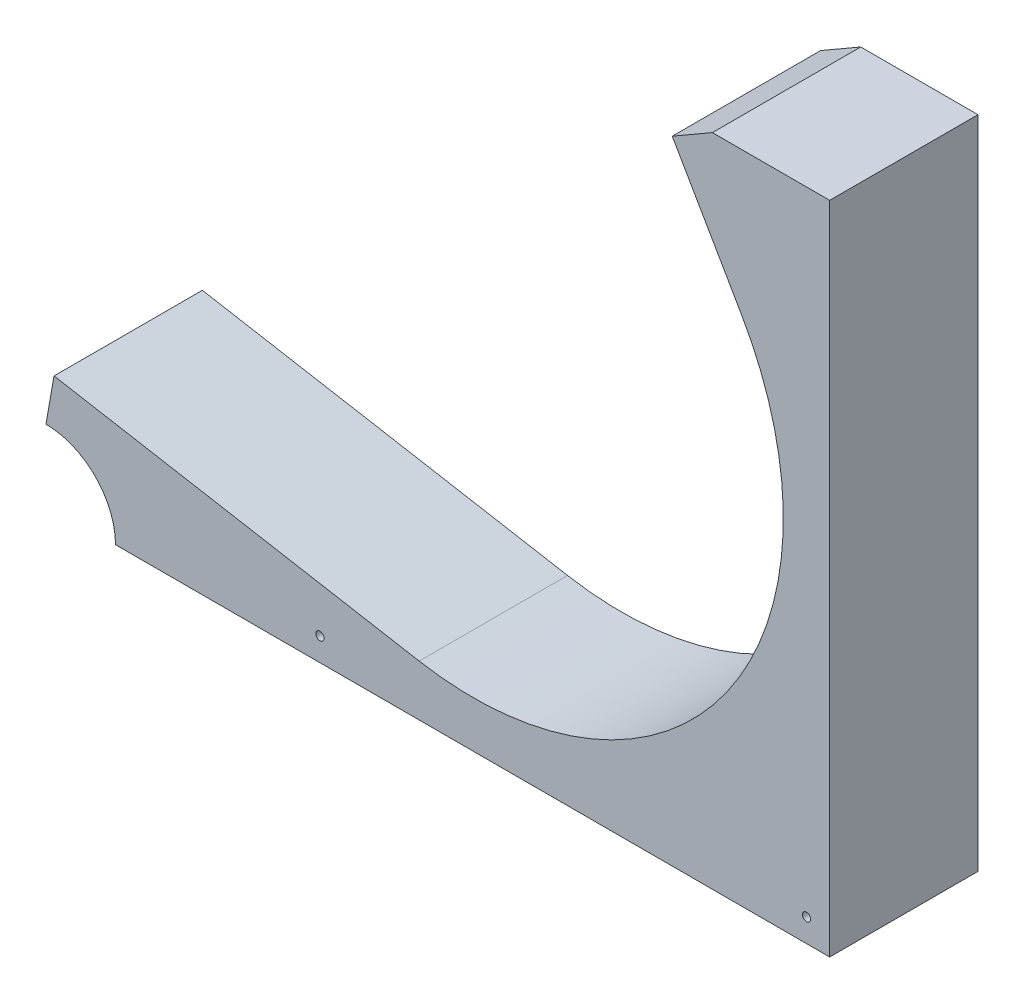
from build123d import *

# Parameters (mm, degrees)
BOSS_EXTRUDE1_DEPTH = 40.64
SKETCH6_R           = 1.1303
CUT_EXTRUDE1_DEPTH  = 158.779215984
SKETCH7_R           = 19.05
CUT_EXTRUDE2_DEPTH  = 158.779215984


with BuildPart() as part:
    # Sweep3: sweep along a path in Sketch2
    with BuildLine(Plane.XY) as sweep3_path:
        Line((-111.378641457, -46.568583299), (-11.322173751, -64.21123815))
        ThreePointArc((-11.322173751, -64.21123815), (53.410187761, -37.398216088), (56.466415172, 32.6009))
        Line((56.466415172, 32.6009), (37.416415172, 65.596467884))
    # 3DSketch1 → Sweep3 (sweep)
    with BuildSketch(Plane(origin=(-117.024291009, -78.586652965, -20.32), x_dir=(0.051794909001673446, 0.2937435257699459, 0.9544799780350292), z_dir=(0.984807753012208, -0.17364817766693055, 0))):
        Polygon((0, 0), (3.788092413, -12.121895721), (42.57815872, 0), (38.790066307, 12.121895721), align=None)
    sweep(path=sweep3_path.line)

    # Sketch5 → Boss-Extrude1 (add)
    with BuildSketch(Plane.XY.offset(20.32)):
        with BuildLine():
            Line((-16.967823303, -96.229307816), (-117.024291009, -78.586652965))
            Line((-117.024291009, -78.586652965), (-117.024291009, -97.7138))
            Line((-117.024291009, -97.7138), (3.02e-07, -97.7138))
            ThreePointArc((3.02e-07, -97.7138), (-8.516318665, -97.341969504), (-16.967823303, -96.229307816))
        make_face()
        with BuildLine():
            ThreePointArc((97.7138, -9e-08), (69.09409067, -69.094090521), (3.02e-07, -97.7138))
            Line((3.02e-07, -97.7138), (97.7138, -97.7138))
            Line((97.7138, -97.7138), (97.7138, -9e-08))
        make_face()
        with BuildLine():
            ThreePointArc((84.6226331, 48.8569), (94.384283017, 25.290192366), (97.7138, -9e-08))
            Line((97.7138, -9e-08), (97.7138, 81.852467884))
            Line((97.7138, 81.852467884), (65.5726331, 81.852467884))
            Line((65.5726331, 81.852467884), (84.6226331, 48.8569))
        make_face()
    extrude(amount=-BOSS_EXTRUDE1_DEPTH)

    # Sketch6 → Cut-Extrude1 (cut, through all)
    with BuildSketch(Plane.XY.offset(20.32)):
        with Locations((91.3638, -91.3638)):
            Circle(SKETCH6_R)
        with Locations((-41.9735, -91.3638)):
            Circle(SKETCH6_R)
    extrude(amount=-CUT_EXTRUDE1_DEPTH, mode=Mode.SUBTRACT)

    # Sketch7 → Cut-Extrude2 (cut, through all)
    with BuildSketch(Plane.XY.offset(20.32)):
        with Locations((-117.024291009, -97.7138)):
            Circle(SKETCH7_R)
    extrude(amount=-CUT_EXTRUDE2_DEPTH, mode=Mode.SUBTRACT)


solid = part.part
